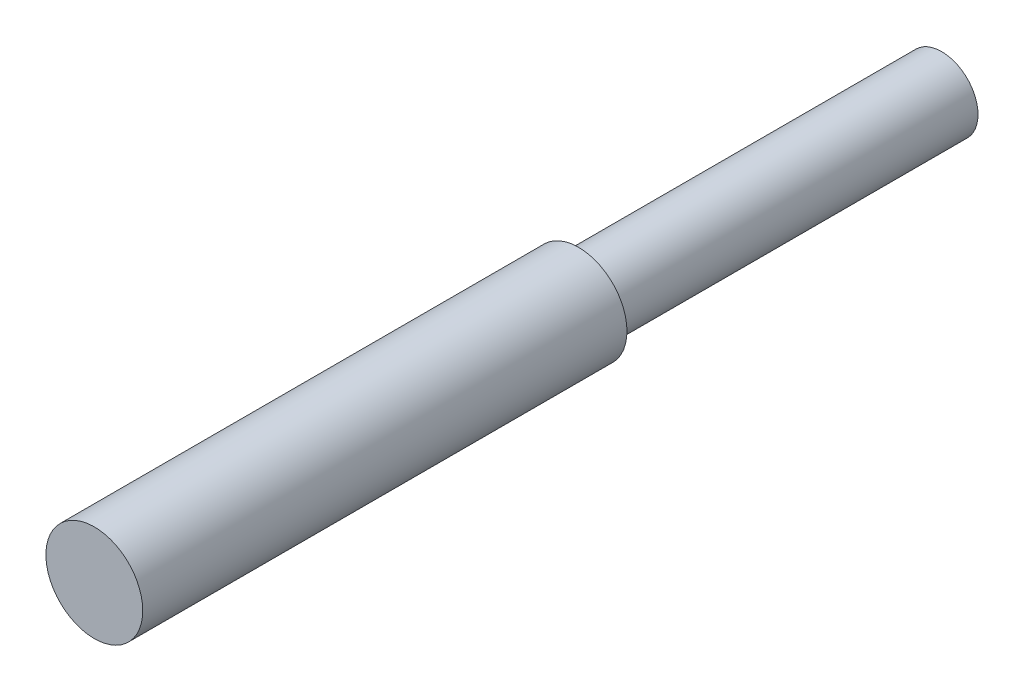
from build123d import *

# Parameters (mm, degrees)
SKETCH1_R           = 15
BOSS_EXTRUDE1_DEPTH = 150
SKETCH2_R           = 20
BOSS_EXTRUDE2_DEPTH = 200


with BuildPart() as part:
    # Sketch1 → Boss-Extrude1 (new body)
    with BuildSketch(Plane.XY):
        Circle(SKETCH1_R)
    extrude(amount=BOSS_EXTRUDE1_DEPTH)

    # Sketch2 → Boss-Extrude2 (add)
    with BuildSketch(Plane.XY.offset(150)):
        Circle(SKETCH2_R)
    extrude(amount=BOSS_EXTRUDE2_DEPTH)


solid = part.part
